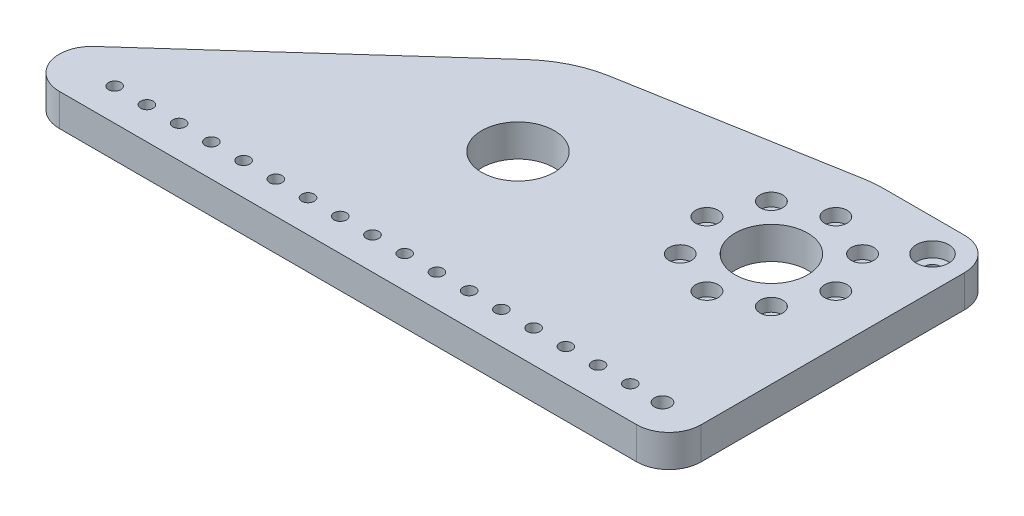
from build123d import *

# Parameters (mm, degrees)
SKETCH1_R                              = 14.2875
SKETCH1_R_2                            = 1.27
INITIAL_PLATE_DEPTH                    = 12.7
PLATE_FILLET_R                         = 12.7
F_10_0_1935_INITIAL_FRONT_BRACE_HOLE_D = 4.9149
SKETCH18_R                             = 2.65745
BOLT_CLEARANCE_DEPTH                   = 13.7
MOUNTING_PATTERN_COUNT                 = 18
MOUNTING_PATTERN_PITCH                 = 12.7
SKETCH21_R                             = 1.27
CHURRO_SUPPORT_PILOT_HOLE_DEPTH        = 13.7
F_1_4_0_25_DIAMETER_HOLE1_D            = 6.35
SKETCH25_R                             = 6.35
BOLT_HEAD_HOLE_DEPTH                   = 5.842
SKETCH12_R                             = 1.27
MAXPLANETARY_PILOT_HOLES_DEPTH         = 13.7
F_10_0_1935_MAXPLANETARY_MOUNTING_D    = 4.9149
SKETCH19_R                             = 2.65745
BOLT_HOLE_CLEARANCE_DEPTH              = 13.7
SKETCH12_3_R                           = 4.445
SKETCH12_3_R_2                         = 1.27
MAX_BOLT_HEAD_CLEARANCE_DEPTH          = 5.08
MAXPLANETARY_MOUNTING_PATTERN_COUNT    = 2
MAXPLANETARY_MOUNTING_PATTERN_ANGLE    = 90


with BuildPart() as part:
    # Sketch1 → Initial Plate (new body)
    with BuildSketch(Plane(origin=(0, 0, 0), x_dir=(1, 0, 0), z_dir=(0, 1, 0))):
        with BuildLine():
            Line((77.181752763, 58.744938329), (-7.718661497, 43.774704621))
            ThreePointArc((-7.718661497, 43.774704621), (-19.485598541, 39.951394838), (-29.742857216, 33.032785904))
            Line((-29.742857216, 33.032785904), (-144.005766802, -69.85))
            Line((-144.005766802, -69.85), (129.35041426, -69.85))
            Line((129.35041426, -69.85), (129.35041426, 59.420233707))
            Line((129.35041426, 59.420233707), (84.900414295, 59.420233707))
            ThreePointArc((84.900414295, 59.420233707), (81.026341512, 59.251088039), (77.181752763, 58.744938329))
        make_face()
        Circle(SKETCH1_R, mode=Mode.SUBTRACT)
        with Locations((84.90041426, 14.970233707)):
            Circle(SKETCH1_R, mode=Mode.SUBTRACT)
        with Locations((114.11041426, -57.15)):
            Circle(SKETCH1_R_2, mode=Mode.SUBTRACT)
    extrude(amount=INITIAL_PLATE_DEPTH)

    # Plate Fillet
    plate_fillet_edges = [part.edges().sort_by_distance(p)[0] for p in [
        (129.35041426, 6.35, 69.85),
        (-144.005766802, 6.35, 69.85),
        (129.35041426, 6.35, -59.420233707),
    ]]
    fillet(plate_fillet_edges, radius=PLATE_FILLET_R)

    # 10 _0.1935_ Initial Front Brace Hole (through all)
    with Locations(Plane(origin=(0, 12.7, 0), x_dir=(1, 0, 0), z_dir=(0, 1, 0))):
        with Locations((114.11041426, -57.15)):
            f_10_0_1935_initial_front_brace_hole = Hole(F_10_0_1935_INITIAL_FRONT_BRACE_HOLE_D / 2)

    # Sketch18 → Bolt Clearance (cut, through all)
    with BuildSketch(Plane(origin=(0, 12.7, 0), x_dir=(1, 0, 0), z_dir=(0, 1, 0))):
        with Locations((114.11041426, -57.15)):
            Circle(SKETCH18_R)
    extrude(amount=-BOLT_CLEARANCE_DEPTH, mode=Mode.SUBTRACT)

    # Mounting Pattern: 10 _0.1935_ Initial Front Brace Hole ×18
    with Locations(*[(-i * MOUNTING_PATTERN_PITCH, 0, 0) for i in range(1, MOUNTING_PATTERN_COUNT)]):
        add(f_10_0_1935_initial_front_brace_hole, mode=Mode.SUBTRACT)

    # Sketch21 → Churro Support Pilot Hole (cut, through all)
    with BuildSketch(Plane(origin=(0, 12.7, 0), x_dir=(1, 0, 0), z_dir=(0, 1, 0))):
        with Locations((116.65041426, 46.720233707)):
            Circle(SKETCH21_R)
    extrude(amount=-CHURRO_SUPPORT_PILOT_HOLE_DEPTH, mode=Mode.SUBTRACT)

    # 1_4 _0.25_ Diameter Hole1 (through all)
    with Locations(Plane(origin=(0, 12.7, 0), x_dir=(1, 0, 0), z_dir=(0, 1, 0))):
        with Locations((116.65041426, 46.720233707), (114.11041426, -57.15)):
            Hole(F_1_4_0_25_DIAMETER_HOLE1_D / 2)

    # Sketch25 → Bolt Head Hole (cut)
    with BuildSketch(Plane(origin=(0, 12.7, 0), x_dir=(1, 0, 0), z_dir=(0, 1, 0))):
        with Locations((116.65041426, 46.720233707)):
            Circle(SKETCH25_R)
    extrude(amount=-BOLT_HEAD_HOLE_DEPTH, mode=Mode.SUBTRACT)

    # Sketch12 → MaxPlanetary Pilot Holes (cut, through all)
    with BuildSketch(Plane(origin=(0, 12.7, 0), x_dir=(1, 0, 0), z_dir=(0, 1, 0))):
        with Locations((66.939902018, 32.93074595)):
            Circle(SKETCH12_R)
        with Locations((59.50041426, 14.970233707)):
            Circle(SKETCH12_R)
        with Locations((110.30041426, 14.970233707)):
            Circle(SKETCH12_R)
        with Locations((102.860926502, -2.990278535)):
            Circle(SKETCH12_R)
    extrude(amount=-MAXPLANETARY_PILOT_HOLES_DEPTH, mode=Mode.SUBTRACT)

    # 10 _0.1935_ MaxPlanetary Mounting (through all)
    with Locations(Plane(origin=(0, 12.7, 0), x_dir=(1, 0, 0), z_dir=(0, 1, 0))):
        with Locations((59.50041426, 14.970233707), (66.939902018, 32.93074595), (110.30041426, 14.970233707), (102.860926502, -2.990278535)):
            f_10_0_1935_maxplanetary_mounting = Hole(F_10_0_1935_MAXPLANETARY_MOUNTING_D / 2)

    # Sketch19 → Bolt Hole Clearance (cut, through all)
    with BuildSketch(Plane(origin=(0, 12.7, 0), x_dir=(1, 0, 0), z_dir=(0, 1, 0))):
        with Locations((66.939902018, 32.93074595)):
            Circle(SKETCH19_R)
        with Locations((59.50041426, 14.970233707)):
            Circle(SKETCH19_R)
        with Locations((110.30041426, 14.970233707)):
            Circle(SKETCH19_R)
        with Locations((102.860926502, -2.990278535)):
            Circle(SKETCH19_R)
    extrude(amount=-BOLT_HOLE_CLEARANCE_DEPTH, mode=Mode.SUBTRACT)

    # Sketch12_3 → Max Bolt Head Clearance (cut)
    with BuildSketch(Plane(origin=(0, 12.7, 0), x_dir=(1, 0, 0), z_dir=(0, 1, 0))):
        with Locations((66.939902018, 32.93074595)):
            Circle(SKETCH12_3_R)
        with Locations((66.939902018, 32.93074595)):
            Circle(SKETCH12_3_R_2, mode=Mode.SUBTRACT)
        with Locations((59.50041426, 14.970233707)):
            Circle(SKETCH12_3_R)
        with Locations((59.50041426, 14.970233707)):
            Circle(SKETCH12_3_R_2, mode=Mode.SUBTRACT)
        with Locations((102.860926502, -2.990278535)):
            Circle(SKETCH12_3_R)
        with Locations((102.860926502, -2.990278535)):
            Circle(SKETCH12_3_R_2, mode=Mode.SUBTRACT)
        with Locations((110.30041426, 14.970233707)):
            Circle(SKETCH12_3_R)
        with Locations((110.30041426, 14.970233707)):
            Circle(SKETCH12_3_R_2, mode=Mode.SUBTRACT)
    max_bolt_head_clearance = extrude(amount=-MAX_BOLT_HEAD_CLEARANCE_DEPTH, mode=Mode.SUBTRACT)

    # MaxPlanetary Mounting Pattern: 10 _0.1935_ MaxPlanetary Mounting, Max Bolt Head Clearance ×2 about axis
    maxplanetary_mounting_pattern_axis = Axis((84.90041426, 0, -14.970233707), (0, 1, 0))
    for i in range(1, MAXPLANETARY_MOUNTING_PATTERN_COUNT):
        add(f_10_0_1935_maxplanetary_mounting.rotate(maxplanetary_mounting_pattern_axis, i * MAXPLANETARY_MOUNTING_PATTERN_ANGLE / (MAXPLANETARY_MOUNTING_PATTERN_COUNT - 1)), mode=Mode.SUBTRACT)
        add(max_bolt_head_clearance.rotate(maxplanetary_mounting_pattern_axis, i * MAXPLANETARY_MOUNTING_PATTERN_ANGLE / (MAXPLANETARY_MOUNTING_PATTERN_COUNT - 1)), mode=Mode.SUBTRACT)


solid = part.part
